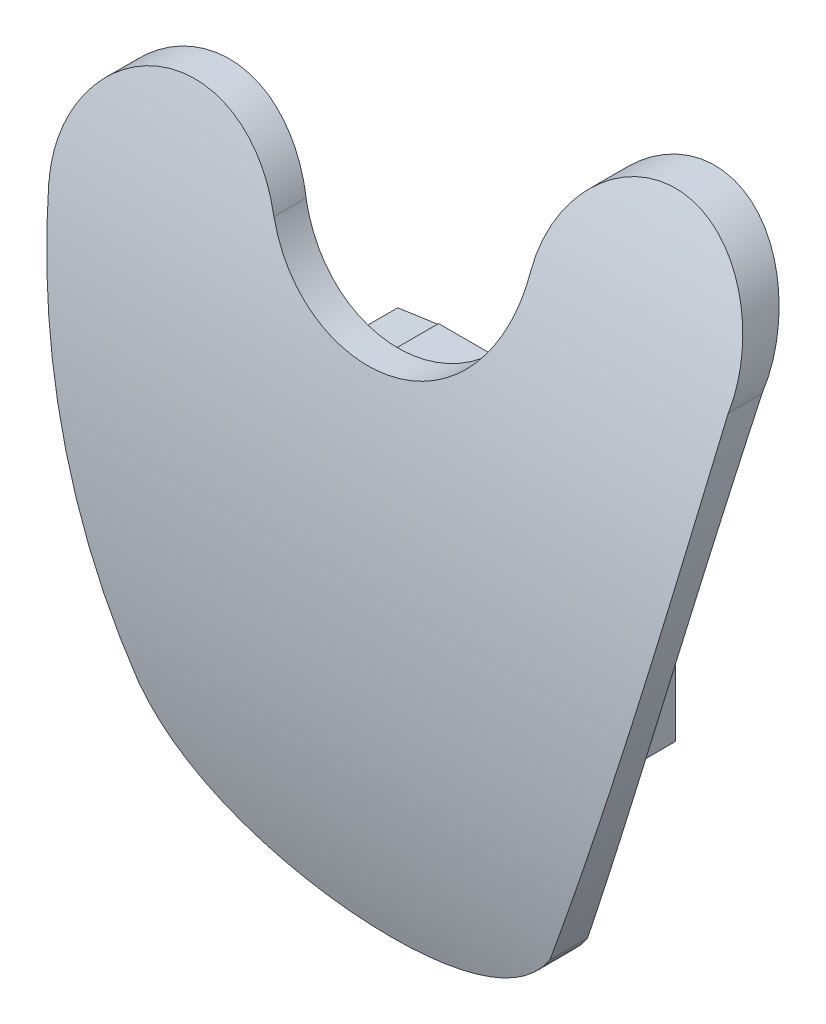
from build123d import *

# Parameters (mm, degrees)
BOSS_EXTRUDE1_DEPTH     = 10
SKETCH3_W               = 26.349262508
SKETCH3_H               = 68.843906453
CUT_EXTRUDE1_DEPTH      = 56.145262863
CUT_EXTRUDE1_DEPTH_BACK = 56.145262863
CUT_EXTRUDE2_DEPTH      = 56.002384149
CUT_EXTRUDE2_DEPTH_BACK = 56.002384149
CUT_EXTRUDE4_DEPTH      = 10
CUT_EXTRUDE5_DEPTH      = 46.333254596
CUT_EXTRUDE5_DEPTH_BACK = 46.333254596
BOSS_EXTRUDE2_START     = -5
BOSS_EXTRUDE2_DEPTH     = 13
BOSS_EXTRUDE4_START     = 7
SKETCH11_W              = 3
SKETCH11_H              = 15.425223653
BOSS_EXTRUDE4_DEPTH     = 15


with BuildPart() as part:
    # Sketch2 → Boss-Extrude1 (new body)
    with BuildSketch(Plane.XY):
        with BuildLine():
            ThreePointArc((20.902943543, -1.119068355), (15.061634654, 6.475690428), (8, 0))
            ThreePointArc((8, 0), (0, -8), (-8, 0))
            ThreePointArc((-8, 0), (-15.061634654, 6.475690428), (-20.902943543, -1.119068355))
            add(Edge.make_bspline(
                [(-20.902943543, -1.119068355), (-19.287028044, -26.367706227), (-3.931804619, -48.088836745)],
                knots=[0, 0, 0, 1, 1, 1], degree=2))
            ThreePointArc((-3.931804619, -48.088836745), (0, -50), (3.931804619, -48.088836745))
            add(Edge.make_bspline(
                [(3.931804619, -48.088836745), (19.287028044, -26.367706227), (20.902943543, -1.119068355)],
                knots=[0.990027735, 0.990027735, 0.990027735, 1.990027735, 1.990027735, 1.990027735], degree=2))
        make_face()
    extrude(amount=BOSS_EXTRUDE1_DEPTH)

    # Sketch3 → Cut-Extrude1 (cut, two sides)
    with BuildSketch(Plane(origin=(0, 0, 0), x_dir=(0, 0, -1), z_dir=(1, 0, 0))) as cut_extrude1_sk:
        with Locations((-0.626059786, -22.605093502)):
            Rectangle(SKETCH3_W, SKETCH3_H)
        with BuildLine():
            Line((-2.5, 6.5), (0, 6.5))
            add(Edge.make_bspline(
                [(0, 6.5), (-14.408545927, -21.081950651), (0, -50)],
                knots=[0, 0, 0, 1, 1, 1], degree=2))
            Line((0, -50), (-2.5, -50))
            add(Edge.make_bspline(
                [(-2.5, 6.5), (-10.733514135, -10.976620558), (-12.053907629, -32.649723791), (-2.5, -50)],
                knots=[0, 0, 0, 0, 1, 1, 1, 1], degree=3))
        make_face(mode=Mode.SUBTRACT)
    extrude(amount=CUT_EXTRUDE1_DEPTH, mode=Mode.SUBTRACT)
    extrude(cut_extrude1_sk.sketch, amount=-CUT_EXTRUDE1_DEPTH_BACK, mode=Mode.SUBTRACT)

    # Sketch6 → Cut-Extrude2 (cut, two sides)
    with BuildSketch(Plane.XY) as cut_extrude2_sk:
        with BuildLine():
            Line((-9.557408926, -39.200378686), (-14.826233878, -49.923840658))
            Line((-14.826233878, -49.923840658), (21.939629108, -53.600426957))
            Line((21.939629108, -53.600426957), (9.557408926, -39.200378686))
            add(Edge.make_bspline(
                [(-9.557408926, -39.200378686), (-5.942899698, -46.006320571), (5.857464148, -45.921239034), (9.557408926, -39.200378686)],
                knots=[0, 0, 0, 0, 1, 1, 1, 1], degree=3))
        make_face()
    extrude(amount=CUT_EXTRUDE2_DEPTH, mode=Mode.SUBTRACT)
    extrude(cut_extrude2_sk.sketch, amount=-CUT_EXTRUDE2_DEPTH_BACK, mode=Mode.SUBTRACT)

    # Sketch8 → Cut-Extrude4 (cut)
    with BuildSketch(Plane.XY):
        with BuildLine():
            Line((-13.816005164, -30.617040202), (-11.76409894, -45.724796066))
            Line((-11.76409894, -45.724796066), (9.724502839, -47.837234885))
            Line((9.724502839, -47.837234885), (13.816005164, -30.617040202))
            add(Edge.make_bspline(
                [(-13.816005164, -30.617040202), (-9.778124174, -41.160624176), (10.772333276, -42.703617762), (13.816005164, -30.617040202)],
                knots=[0, 0, 0, 0, 1, 1, 1, 1], degree=3))
        make_face()
    extrude(amount=CUT_EXTRUDE4_DEPTH, mode=Mode.SUBTRACT)

    # Sketch9 → Cut-Extrude5 (cut, two sides)
    with BuildSketch(Plane.XY) as cut_extrude5_sk:
        with BuildLine():
            Line((-28.08585552, 3.22203692), (-20.178308463, -8.029241074))
            ThreePointArc((-20.178308463, -8.029241074), (-15.362673917, -0.358132046), (-7.0095805, -3.859857359))
            Line((-7.0095805, -3.859857359), (-4.822672945, -1.298112458))
            Line((-4.822672945, -1.298112458), (-10.044224813, 8.365655178))
            Line((-10.044224813, 8.365655178), (-28.08585552, 3.22203692))
        make_face()
    extrude(amount=CUT_EXTRUDE5_DEPTH, mode=Mode.SUBTRACT)
    extrude(cut_extrude5_sk.sketch, amount=-CUT_EXTRUDE5_DEPTH_BACK, mode=Mode.SUBTRACT)

    # Sketch10 → Boss-Extrude2 (add)
    with BuildSketch(Plane.XY.offset(BOSS_EXTRUDE2_START)):
        Polygon((-7.615886076, -15.930661374), (-5.468083043, -30.930661374), (-8.437794283, -31.355885027), (-10.585597315, -16.355885027), align=None)
    extrude(amount=BOSS_EXTRUDE2_DEPTH)

    # Sketch11 → Boss-Extrude4 (add)
    with BuildSketch(Plane(origin=(0, 0, 0), x_dir=(0, 0, -1), z_dir=(1, 0, 0)).offset(BOSS_EXTRUDE4_START)):
        with Locations((3.5, -23.643273201)):
            Rectangle(SKETCH11_W, SKETCH11_H)
    extrude(amount=-BOSS_EXTRUDE4_DEPTH)


solid = part.part
